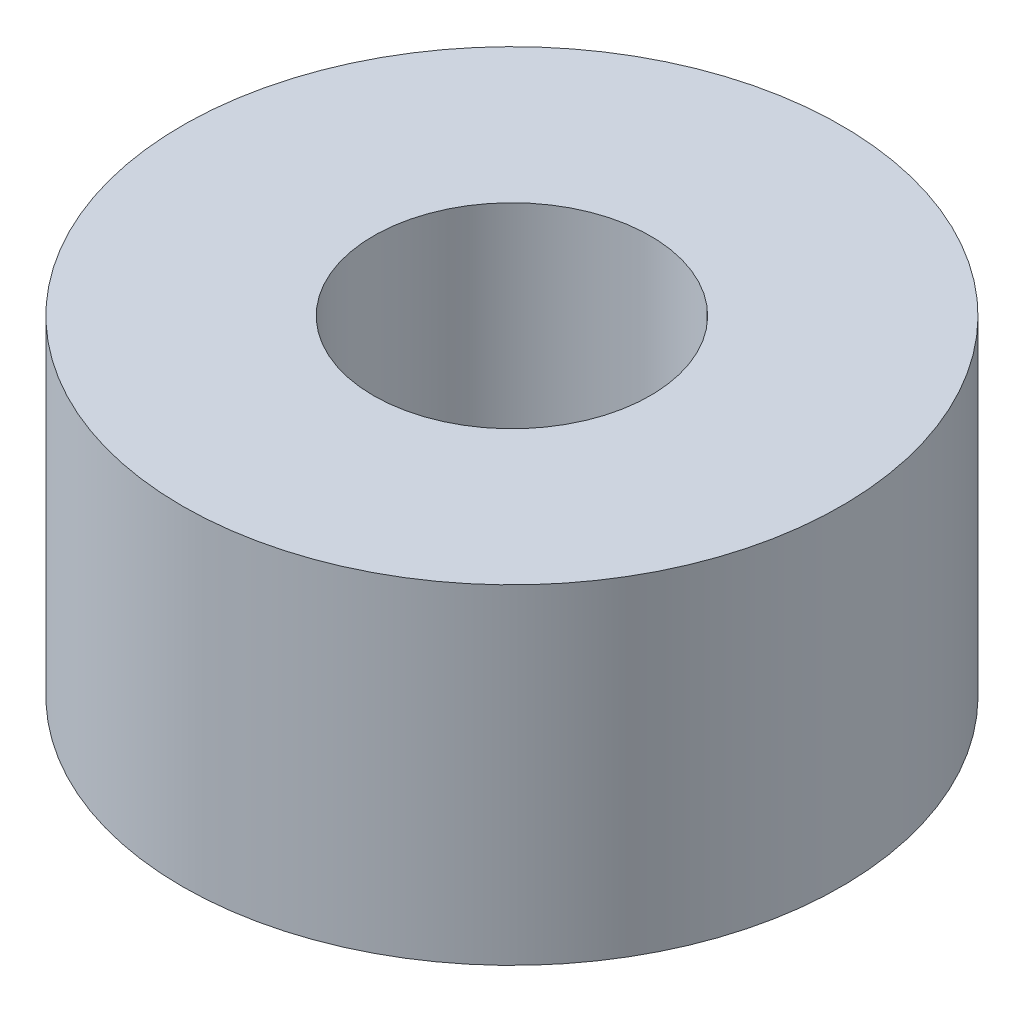
from build123d import *

# Parameters (mm, degrees)
SKETCH1_W = 5.5245
SKETCH1_H = 9.525


with BuildPart() as part:
    # Sketch1 → Revolve1 (revolve)
    with BuildSketch(Plane.XY):
        with Locations((6.76275, 0)):
            Rectangle(SKETCH1_W, SKETCH1_H)
    revolve(axis=Axis((0, 4.7625, 0), (0, -1, 0)))


solid = part.part
